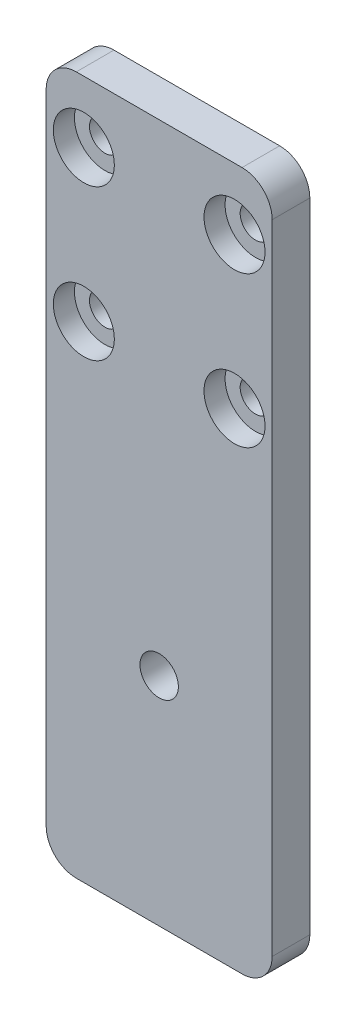
from build123d import *

# Parameters (mm, degrees)
CROQUIS1_W              = 30
CROQUIS1_H              = 75
CROQUIS1_R              = 2.05
CROQUIS1_R_2            = 2.55
SALIENTE_EXTRUIR1_DEPTH = 5
CROQUIS4_R              = 4.05
CORTAR_EXTRUIR1_DEPTH   = 2.8
CROQUIS5_W              = 30
CROQUIS5_H              = 17.7
SALIENTE_EXTRUIR2_DEPTH = 5
REDONDEO1_R             = 4


with BuildPart() as part:
    # Croquis1 → Saliente-Extruir1 (new body)
    with BuildSketch(Plane.XY):
        with Locations((15, 37.5)):
            Rectangle(CROQUIS1_W, CROQUIS1_H)
        with Locations((5, 66.8)):
            Circle(CROQUIS1_R, mode=Mode.SUBTRACT)
        with Locations((25, 66.8)):
            Circle(CROQUIS1_R, mode=Mode.SUBTRACT)
        with Locations((25, 46.8)):
            Circle(CROQUIS1_R, mode=Mode.SUBTRACT)
        with Locations((5, 46.8)):
            Circle(CROQUIS1_R, mode=Mode.SUBTRACT)
        with Locations((15, 11.08)):
            Circle(CROQUIS1_R_2, mode=Mode.SUBTRACT)
    extrude(amount=SALIENTE_EXTRUIR1_DEPTH)

    # Croquis4 → Cortar-Extruir1 (cut)
    with BuildSketch(Plane.XY.offset(5)):
        with Locations((5, 66.8)):
            Circle(CROQUIS4_R)
        with Locations((5, 46.8)):
            Circle(CROQUIS4_R)
        with Locations((25, 46.8)):
            Circle(CROQUIS4_R)
        with Locations((25, 66.8)):
            Circle(CROQUIS4_R)
    extrude(amount=-CORTAR_EXTRUIR1_DEPTH, mode=Mode.SUBTRACT)

    # Croquis5 → Saliente-Extruir2 (add, through all)
    with BuildSketch(Plane.XY.offset(5)):
        with Locations((15, -8.85)):
            Rectangle(CROQUIS5_W, CROQUIS5_H)
    extrude(amount=-SALIENTE_EXTRUIR2_DEPTH)

    # Redondeo1
    redondeo1_edges = [part.edges().sort_by_distance(p)[0] for p in [
        (0, -17.7, 2.5),
        (30, -17.7, 2.5),
        (0, 75, 2.5),
        (30, 75, 2.5),
    ]]
    fillet(redondeo1_edges, radius=REDONDEO1_R)


solid = part.part
